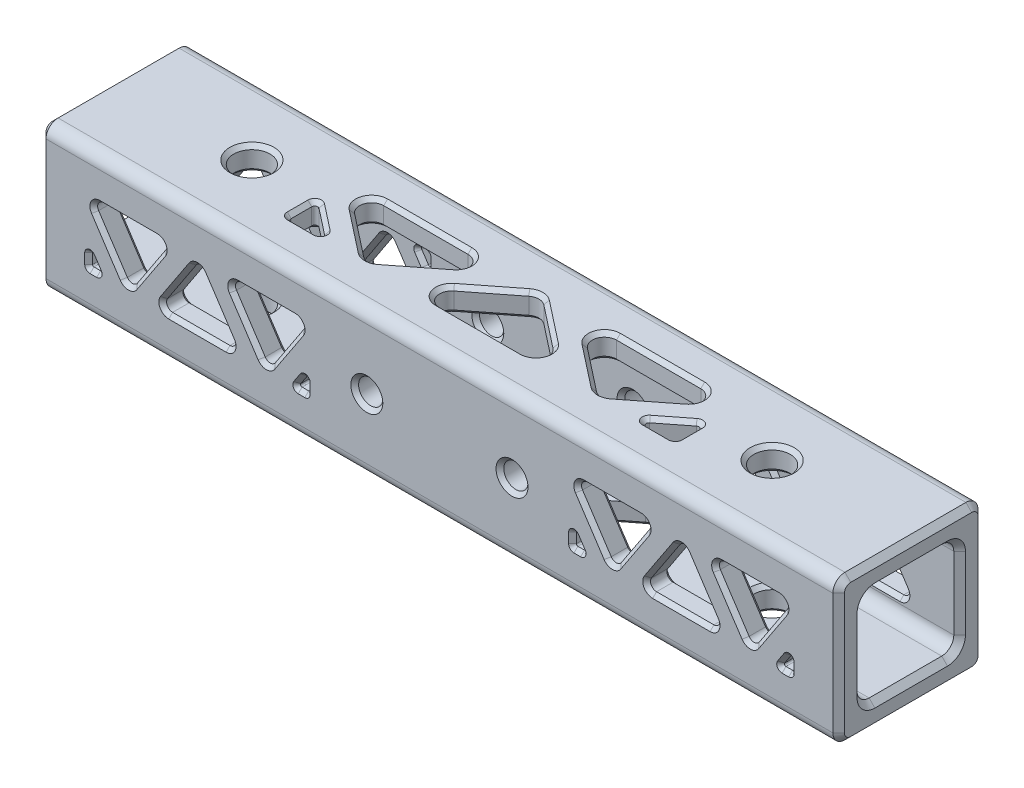
from build123d import *

# Parameters (mm, degrees)
SKETCH1_W                      = 19.05
SKETCH1_H                      = 19.05
SKETCH1_W_2                    = 12.7
SKETCH1_H_2                    = 12.7
BOSS_EXTRUDE1_DEPTH            = 52.3875
F_3_16_0_1875_DIAMETER_HOLE1_D = 4.7625
F_1_8_0_125_DIAMETER_HOLE1_D   = 3.175
CUT_EXTRUDE1_DEPTH             = 3.175
CUT_EXTRUDE2_DEPTH             = 3.175
CIRPATTERN1_COUNT              = 2
CIRPATTERN2_COUNT              = 2
FILLET1_R                      = 1.5875
FILLET4_R                      = 0.79375
FILLET2_R                      = 0.396875
FILLET3_R                      = 0.1984375
CHAMFER1_SIZE                  = 0.762
CHAMFER2_SIZE                  = 0.508


with BuildPart() as part:
    # Sketch1 → Boss-Extrude1 (new body, symmetric)
    with BuildSketch(Plane(origin=(0, 0, 0), x_dir=(0, 0, -1), z_dir=(1, 0, 0))):
        Rectangle(SKETCH1_W, SKETCH1_H)
        Rectangle(SKETCH1_W_2, SKETCH1_H_2, mode=Mode.SUBTRACT)
    extrude(amount=BOSS_EXTRUDE1_DEPTH, both=True)

    # 3/16 (0.1875) Diameter Hole1 (through all)
    with Locations(Plane(origin=(0, 9.525, 0), x_dir=(1, 0, 0), z_dir=(0, 1, 0))):
        with Locations((-34.13125, 0), (34.13125, 0)):
            Hole(F_3_16_0_1875_DIAMETER_HOLE1_D / 2)

    # 1/8 (0.125) Diameter Hole1 (through all)
    with Locations(Plane(origin=(0, 0, -9.525), x_dir=(-1, 0, 0), z_dir=(0, 0, -1))):
        with Locations((-9.525, 0), (9.525, 0)):
            Hole(F_1_8_0_125_DIAMETER_HOLE1_D / 2)

    # Sketch8 → Cut-Extrude1 (cut)
    with BuildSketch(Plane(origin=(0, 9.525, 0), x_dir=(1, 0, 0), z_dir=(0, 1, 0))):
        Polygon((-25.4, -0.065347152), (-25.4, -3.96875), (-20.420043773, -3.96875), align=None)
        Polygon((-25.4, 3.96875), (-15.273347924, -3.96875), (-5.146695849, 3.96875), align=None)
        Polygon((-10.126652076, -3.96875), (0, 3.96875), (10.126652076, -3.96875), align=None)
        Polygon((25.4, 3.96875), (15.273347924, -3.96875), (5.146695849, 3.96875), align=None)
        Polygon((25.4, -3.96875), (25.4, -0.065347152), (20.420043773, -3.96875), align=None)
    cut_extrude1 = extrude(amount=-CUT_EXTRUDE1_DEPTH, mode=Mode.SUBTRACT)

    # Sketch9 → Cut-Extrude2 (cut)
    with BuildSketch(Plane.XY.offset(9.525)):
        Polygon((-46.0375, 3.96875), (-40.796126441, -3.96875), (-35.554752881, 3.96875), align=None)
        Polygon((-36.991373559, -3.96875), (-31.75, 3.96875), (-26.508626441, -3.96875), align=None)
        Polygon((-17.4625, 3.96875), (-22.703873559, -3.96875), (-27.945247119, 3.96875), align=None)
        Polygon((-46.0375, -1.793141545), (-46.0375, -3.96875), (-44.600879322, -3.96875), align=None)
        Polygon((-17.4625, -3.96875), (-17.4625, -1.793141545), (-18.899120678, -3.96875), align=None)
        Polygon((17.4625, 3.96875), (22.703873559, -3.96875), (27.945247119, 3.96875), align=None)
        Polygon((26.508626441, -3.96875), (31.75, 3.96875), (36.991373559, -3.96875), align=None)
        Polygon((46.0375, 3.96875), (40.796126441, -3.96875), (35.554752881, 3.96875), align=None)
        Polygon((17.4625, -1.793141545), (17.4625, -3.96875), (18.899120678, -3.96875), align=None)
        Polygon((46.0375, -1.793141545), (46.0375, -3.96875), (44.600879322, -3.96875), align=None)
    cut_extrude2 = extrude(amount=-CUT_EXTRUDE2_DEPTH, mode=Mode.SUBTRACT)

    # CirPattern1: Cut-Extrude1 ×2 about axis
    cirpattern1_axis = Axis((57.62625, 0, 0), (-1, 0, 0))
    for i in range(1, CIRPATTERN1_COUNT):
        add(cut_extrude1.rotate(cirpattern1_axis, i * 360 / CIRPATTERN1_COUNT), mode=Mode.SUBTRACT)

    # CirPattern2: Cut-Extrude2 ×2 about axis
    cirpattern2_axis = Axis((57.62625, 0, 0), (-1, 0, 0))
    for i in range(1, CIRPATTERN2_COUNT):
        add(cut_extrude2.rotate(cirpattern2_axis, i * 360 / CIRPATTERN2_COUNT), mode=Mode.SUBTRACT)

    # Fillet1
    fillet1_edges = [part.edges().sort_by_distance(p)[0] for p in [
        (0, -6.35, -6.35),
        (0, 6.35, -6.35),
        (0, 6.35, 6.35),
        (0, -6.35, 6.35),
        (5.146695849, -7.9375, 3.96875),
        (25.4, -7.9375, 3.96875),
        (15.273347924, -7.9375, -3.96875),
        (10.126652076, -7.9375, -3.96875),
        (0, -7.9375, 3.96875),
        (-10.126652076, -7.9375, -3.96875),
        (-25.4, -7.9375, 3.96875),
        (-5.146695849, -7.9375, 3.96875),
        (-15.273347924, -7.9375, -3.96875),
        (0, -9.525, -9.525),
        (0, -9.525, 9.525),
        (0, 9.525, 9.525),
        (0, 9.525, -9.525),
        (5.146695849, 7.9375, -3.96875),
        (25.4, 7.9375, -3.96875),
        (15.273347924, 7.9375, 3.96875),
        (0, 7.9375, -3.96875),
        (10.126652076, 7.9375, 3.96875),
        (-10.126652076, 7.9375, 3.96875),
        (-25.4, 7.9375, -3.96875),
        (-5.146695849, 7.9375, -3.96875),
        (-15.273347924, 7.9375, 3.96875),
    ]]
    fillet(fillet1_edges, radius=FILLET1_R)

    # Fillet4
    fillet4_edges = [part.edges().sort_by_distance(p)[0] for p in [
        (-22.703873559, -3.96875, 7.9375),
        (-17.4625, 3.96875, 7.9375),
        (-27.945247119, 3.96875, 7.9375),
        (-40.796126441, -3.96875, 7.9375),
        (-35.554752881, 3.96875, 7.9375),
        (-46.0375, 3.96875, 7.9375),
        (22.703873559, -3.96875, 7.9375),
        (27.945247119, 3.96875, 7.9375),
        (17.4625, 3.96875, 7.9375),
        (40.796126441, -3.96875, 7.9375),
        (46.0375, 3.96875, 7.9375),
        (35.554752881, 3.96875, 7.9375),
        (26.508626441, -3.96875, 7.9375),
        (36.991373559, -3.96875, 7.9375),
        (31.75, 3.96875, 7.9375),
        (-36.991373559, -3.96875, 7.9375),
        (-26.508626441, -3.96875, 7.9375),
        (-31.75, 3.96875, 7.9375),
        (-27.945247119, -3.96875, -7.9375),
        (-17.4625, -3.96875, -7.9375),
        (-22.703873559, 3.96875, -7.9375),
        (-46.0375, -3.96875, -7.9375),
        (-35.554752881, -3.96875, -7.9375),
        (-40.796126441, 3.96875, -7.9375),
        (17.4625, -3.96875, -7.9375),
        (27.945247119, -3.96875, -7.9375),
        (22.703873559, 3.96875, -7.9375),
        (35.554752881, -3.96875, -7.9375),
        (46.0375, -3.96875, -7.9375),
        (40.796126441, 3.96875, -7.9375),
        (36.991373559, 3.96875, -7.9375),
        (31.75, -3.96875, -7.9375),
        (26.508626441, 3.96875, -7.9375),
        (-26.508626441, 3.96875, -7.9375),
        (-31.75, -3.96875, -7.9375),
        (-36.991373559, 3.96875, -7.9375),
    ]]
    fillet(fillet4_edges, radius=FILLET4_R)

    # Fillet2
    fillet2_edges = [part.edges().sort_by_distance(p)[0] for p in [
        (25.4, -7.9375, -3.96875),
        (20.420043773, -7.9375, -3.96875),
        (25.4, -7.9375, -0.065347152),
        (-20.420043773, -7.9375, -3.96875),
        (-25.4, -7.9375, -3.96875),
        (-25.4, -7.9375, -0.065347152),
        (25.4, 7.9375, 3.96875),
        (20.420043773, 7.9375, 3.96875),
        (25.4, 7.9375, 0.065347152),
        (-20.420043773, 7.9375, 3.96875),
        (-25.4, 7.9375, 3.96875),
        (-25.4, 7.9375, 0.065347152),
    ]]
    fillet(fillet2_edges, radius=FILLET2_R)

    # Fillet3
    fillet3_edges = [part.edges().sort_by_distance(p)[0] for p in [
        (-17.4625, -1.793141545, 7.9375),
        (-18.899120678, -3.96875, 7.9375),
        (-17.4625, -3.96875, 7.9375),
        (-46.0375, -1.793141545, 7.9375),
        (-46.0375, -3.96875, 7.9375),
        (-44.600879322, -3.96875, 7.9375),
        (17.4625, -1.793141545, 7.9375),
        (17.4625, -3.96875, 7.9375),
        (18.899120678, -3.96875, 7.9375),
        (46.0375, -1.793141545, 7.9375),
        (44.600879322, -3.96875, 7.9375),
        (46.0375, -3.96875, 7.9375),
        (-17.4625, 3.96875, -7.9375),
        (-17.4625, 1.793141545, -7.9375),
        (-18.899120678, 3.96875, -7.9375),
        (-44.600879322, 3.96875, -7.9375),
        (-46.0375, 3.96875, -7.9375),
        (-46.0375, 1.793141545, -7.9375),
        (18.899120678, 3.96875, -7.9375),
        (17.4625, 3.96875, -7.9375),
        (17.4625, 1.793141545, -7.9375),
        (46.0375, 3.96875, -7.9375),
        (46.0375, 1.793141545, -7.9375),
        (44.600879322, 3.96875, -7.9375),
    ]]
    fillet(fillet3_edges, radius=FILLET3_R)

    # Chamfer1
    chamfer1_edges = [part.edges().sort_by_distance(p)[0] for p in [
        (-52.3875, -6.35, 0),
        (52.3875, -6.35, 0),
        (-52.3875, 0, -6.35),
        (52.3875, 0, -6.35),
        (-52.3875, 6.35, 0),
        (52.3875, 6.35, 0),
        (-52.3875, 0, 6.35),
        (52.3875, 0, 6.35),
        (-52.3875, 0, -9.525),
        (52.3875, 0, -9.525),
        (-52.3875, -9.525, 0),
        (-52.3875, 0, 9.525),
        (-52.3875, 9.525, 0),
        (-52.3875, 9.060032015, 9.060032015),
        (-52.3875, -9.060032015, 9.060032015),
        (-52.3875, 9.060032015, -9.060032015),
        (-52.3875, -9.060032015, -9.060032015),
        (52.3875, -9.525, 0),
        (52.3875, 9.525, 0),
        (52.3875, 0, 9.525),
        (52.3875, 9.060032015, 9.060032015),
        (52.3875, -9.060032015, 9.060032015),
        (52.3875, 9.060032015, -9.060032015),
        (52.3875, -9.060032015, -9.060032015),
        (-52.3875, -5.885032015, -5.885032015),
        (52.3875, -5.885032015, -5.885032015),
        (-52.3875, 5.885032015, -5.885032015),
        (52.3875, 5.885032015, -5.885032015),
        (-52.3875, 5.885032015, 5.885032015),
        (52.3875, 5.885032015, 5.885032015),
        (-52.3875, -5.885032015, 5.885032015),
        (52.3875, -5.885032015, 5.885032015),
    ]]
    chamfer(chamfer1_edges, length=CHAMFER1_SIZE)

    # Chamfer2
    chamfer2_edges = [part.edges().sort_by_distance(p)[0] for p in [
        (36.5125, 6.35, 0),
        (36.5125, -6.35, 0),
        (36.5125, -9.525, 0),
        (36.5125, 9.525, 0),
        (15.273347924, -9.525, 3.96875),
        (15.273347924, -6.35, 3.96875),
        (19.01666457, -9.525, -1.034653356),
        (19.01666457, -6.35, -1.034653356),
        (11.530031279, -9.525, -1.034653356),
        (11.530031279, -6.35, -1.034653356),
        (-3.743316645, -9.525, 1.034653356),
        (-3.743316645, -6.35, 1.034653356),
        (3.743316645, -9.525, 1.034653356),
        (3.743316645, -6.35, 1.034653356),
        (0, -9.525, -3.96875),
        (0, -6.35, -3.96875),
        (-15.273347924, -9.525, 3.96875),
        (-15.273347924, -6.35, 3.96875),
        (-31.75, 6.35, 0),
        (-31.75, -6.35, 0),
        (-11.530031279, -9.525, -1.034653356),
        (-11.530031279, -6.35, -1.034653356),
        (-31.75, -9.525, 0),
        (-31.75, 9.525, 0),
        (-19.01666457, -9.525, -1.034653356),
        (-19.01666457, -6.35, -1.034653356),
        (15.273347924, 9.525, -3.96875),
        (15.273347924, 6.35, -3.96875),
        (19.01666457, 9.525, 1.034653356),
        (19.01666457, 6.35, 1.034653356),
        (11.530031279, 9.525, 1.034653356),
        (11.530031279, 6.35, 1.034653356),
        (3.743316645, 9.525, -1.034653356),
        (3.743316645, 6.35, -1.034653356),
        (0, 9.525, 3.96875),
        (0, 6.35, 3.96875),
        (-3.743316645, 9.525, -1.034653356),
        (-3.743316645, 6.35, -1.034653356),
        (-15.273347924, 9.525, -3.96875),
        (-15.273347924, 6.35, -3.96875),
        (-11.530031279, 9.525, 1.034653356),
        (-11.530031279, 6.35, 1.034653356),
        (-19.01666457, 9.525, 1.034653356),
        (-19.01666457, 6.35, 1.034653356),
        (22.301925311, -9.525, 2.899270205),
        (22.301925311, -6.35, 2.899270205),
        (8.244770538, -9.525, 2.899270205),
        (8.244770538, -6.35, 2.899270205),
        (15.273347924, -9.525, -3.539201424),
        (15.273347924, -6.35, -3.539201424),
        (0, -9.525, 3.539201424),
        (0, -6.35, 3.539201424),
        (7.028577387, -9.525, -2.899270205),
        (7.028577387, -6.35, -2.899270205),
        (-7.028577387, -9.525, -2.899270205),
        (-7.028577387, -6.35, -2.899270205),
        (-8.244770538, -9.525, 2.899270205),
        (-8.244770538, -6.35, 2.899270205),
        (-22.301925311, -9.525, 2.899270205),
        (-22.301925311, -6.35, 2.899270205),
        (-15.273347924, -9.525, -3.539201424),
        (-15.273347924, -6.35, -3.539201424),
        (22.301925311, 9.525, -2.899270205),
        (22.301925311, 6.35, -2.899270205),
        (8.244770538, 9.525, -2.899270205),
        (8.244770538, 6.35, -2.899270205),
        (15.273347924, 9.525, 3.539201424),
        (15.273347924, 6.35, 3.539201424),
        (7.028577387, 9.525, 2.899270205),
        (7.028577387, 6.35, 2.899270205),
        (0, 9.525, -3.539201424),
        (0, 6.35, -3.539201424),
        (-7.028577387, 9.525, 2.899270205),
        (-7.028577387, 6.35, 2.899270205),
        (-8.244770538, 9.525, -2.899270205),
        (-8.244770538, 6.35, -2.899270205),
        (-22.301925311, 9.525, -2.899270205),
        (-22.301925311, 6.35, -2.899270205),
        (-15.273347924, 9.525, 3.539201424),
        (-15.273347924, 6.35, 3.539201424),
        (7.9375, 0, 6.35),
        (7.9375, 0, -6.35),
        (7.9375, 0, -9.525),
        (7.9375, 0, 9.525),
        (-38.250731901, 0.11402205, -9.525),
        (-38.250731901, 0.11402205, -6.35),
        (-43.34152098, 0.11402205, -9.525),
        (-43.34152098, 0.11402205, -6.35),
        (-40.796126441, -3.96875, -9.525),
        (-40.796126441, -3.96875, -6.35),
        (-31.75, 3.96875, -9.525),
        (-31.75, 3.96875, -6.35),
        (-34.295394539, -0.11402205, -9.525),
        (-34.295394539, -0.11402205, -6.35),
        (-29.204605461, -0.11402205, -9.525),
        (-29.204605461, -0.11402205, -6.35),
        (-25.249268099, 0.11402205, -9.525),
        (-25.249268099, 0.11402205, -6.35),
        (-22.703873559, -3.96875, -9.525),
        (-22.703873559, -3.96875, -6.35),
        (-20.15847902, 0.11402205, -9.525),
        (-20.15847902, 0.11402205, -6.35),
        (20.15847902, 0.11402205, -9.525),
        (20.15847902, 0.11402205, -6.35),
        (22.703873559, -3.96875, -9.525),
        (22.703873559, -3.96875, -6.35),
        (25.249268099, 0.11402205, -9.525),
        (25.249268099, 0.11402205, -6.35),
        (31.75, 3.96875, -9.525),
        (-11.1125, 0, -6.35),
        (31.75, 3.96875, -6.35),
        (-11.1125, 0, 6.35),
        (29.204605461, -0.11402205, -9.525),
        (-11.1125, 0, 9.525),
        (29.204605461, -0.11402205, -6.35),
        (-11.1125, 0, -9.525),
        (34.295394539, -0.11402205, -9.525),
        (34.295394539, -0.11402205, -6.35),
        (38.250731901, 0.11402205, -9.525),
        (38.250731901, 0.11402205, -6.35),
        (40.796126441, -3.96875, -9.525),
        (40.796126441, -3.96875, -6.35),
        (43.34152098, 0.11402205, -9.525),
        (43.34152098, 0.11402205, -6.35),
        (40.796126441, 3.96875, 9.525),
        (40.796126441, 3.96875, 6.35),
        (43.34152098, -0.11402205, 9.525),
        (43.34152098, -0.11402205, 6.35),
        (38.250731901, -0.11402205, 9.525),
        (38.250731901, -0.11402205, 6.35),
        (29.204605461, 0.11402205, 9.525),
        (29.204605461, 0.11402205, 6.35),
        (34.295394539, 0.11402205, 9.525),
        (34.295394539, 0.11402205, 6.35),
        (31.75, -3.96875, 9.525),
        (31.75, -3.96875, 6.35),
        (20.15847902, -0.11402205, 9.525),
        (20.15847902, -0.11402205, 6.35),
        (22.703873559, 3.96875, 9.525),
        (22.703873559, 3.96875, 6.35),
        (25.249268099, -0.11402205, 9.525),
        (25.249268099, -0.11402205, 6.35),
        (-22.703873559, 3.96875, 9.525),
        (-22.703873559, 3.96875, 6.35),
        (-20.15847902, -0.11402205, 9.525),
        (-20.15847902, -0.11402205, 6.35),
        (-25.249268099, -0.11402205, 9.525),
        (-25.249268099, -0.11402205, 6.35),
        (-29.204605461, 0.11402205, 9.525),
        (-29.204605461, 0.11402205, 6.35),
        (-31.75, -3.96875, 9.525),
        (-31.75, -3.96875, 6.35),
        (-34.295394539, 0.11402205, 9.525),
        (-34.295394539, 0.11402205, 6.35),
        (-40.796126441, 3.96875, 9.525),
        (-40.796126441, 3.96875, 6.35),
        (-38.250731901, -0.11402205, 9.525),
        (-38.250731901, -0.11402205, 6.35),
        (-43.34152098, -0.11402205, 9.525),
        (-43.34152098, -0.11402205, 6.35),
        (-40.796126441, 3.322027114, -9.525),
        (-40.796126441, 3.322027114, -6.35),
        (-45.261178075, -3.551075734, -9.525),
        (-45.261178075, -3.551075734, -6.35),
        (-36.331074806, -3.551075734, -9.525),
        (-36.331074806, -3.551075734, -6.35),
        (-36.215051635, 3.551075734, -9.525),
        (-36.215051635, 3.551075734, -6.35),
        (-27.284948365, 3.551075734, -9.525),
        (-27.284948365, 3.551075734, -6.35),
        (-31.75, -3.322027114, -9.525),
        (-31.75, -3.322027114, -6.35),
        (-27.168925194, -3.551075734, -9.525),
        (-27.168925194, -3.551075734, -6.35),
        (-18.238821925, -3.551075734, -9.525),
        (-18.238821925, -3.551075734, -6.35),
        (-22.703873559, 3.322027114, -9.525),
        (-22.703873559, 3.322027114, -6.35),
        (18.238821925, -3.551075734, -9.525),
        (18.238821925, -3.551075734, -6.35),
        (27.168925194, -3.551075734, -9.525),
        (27.168925194, -3.551075734, -6.35),
        (22.703873559, 3.322027114, -9.525),
        (22.703873559, 3.322027114, -6.35),
        (27.284948365, 3.551075734, -9.525),
        (27.284948365, 3.551075734, -6.35),
        (36.215051635, 3.551075734, -9.525),
        (36.215051635, 3.551075734, -6.35),
        (31.75, -3.322027114, -9.525),
        (31.75, -3.322027114, -6.35),
        (36.331074806, -3.551075734, -9.525),
        (36.331074806, -3.551075734, -6.35),
        (40.796126441, 3.322027114, -9.525),
        (40.796126441, 3.322027114, -6.35),
        (45.261178075, -3.551075734, -9.525),
        (45.261178075, -3.551075734, -6.35),
        (45.261178075, 3.551075734, 9.525),
        (45.261178075, 3.551075734, 6.35),
        (40.796126441, -3.322027114, 9.525),
        (40.796126441, -3.322027114, 6.35),
        (36.331074806, 3.551075734, 9.525),
        (36.331074806, 3.551075734, 6.35),
        (31.75, 3.322027114, 9.525),
        (31.75, 3.322027114, 6.35),
        (36.215051635, -3.551075734, 9.525),
        (36.215051635, -3.551075734, 6.35),
        (27.284948365, -3.551075734, 9.525),
        (27.284948365, -3.551075734, 6.35),
        (18.238821925, 3.551075734, 9.525),
        (18.238821925, 3.551075734, 6.35),
        (27.168925194, 3.551075734, 9.525),
        (27.168925194, 3.551075734, 6.35),
        (22.703873559, -3.322027114, 9.525),
        (22.703873559, -3.322027114, 6.35),
        (-18.238821925, 3.551075734, 9.525),
        (-18.238821925, 3.551075734, 6.35),
        (-22.703873559, -3.322027114, 9.525),
        (-22.703873559, -3.322027114, 6.35),
        (-27.168925194, 3.551075734, 9.525),
        (-27.168925194, 3.551075734, 6.35),
        (-27.284948365, -3.551075734, 9.525),
        (-27.284948365, -3.551075734, 6.35),
        (-36.215051635, -3.551075734, 9.525),
        (-36.215051635, -3.551075734, 6.35),
        (-31.75, 3.322027114, 9.525),
        (-31.75, 3.322027114, 6.35),
        (-36.331074806, 3.551075734, 9.525),
        (-36.331074806, 3.551075734, 6.35),
        (-40.796126441, -3.322027114, 9.525),
        (-40.796126441, -3.322027114, 6.35),
        (-45.261178075, 3.551075734, 9.525),
        (-45.261178075, 3.551075734, 6.35),
        (23.286419179, 9.525, 3.96875),
        (23.286419179, 6.35, 3.96875),
        (23.041586735, 9.525, 1.913925059),
        (23.041586735, 6.35, 1.913925059),
        (25.4, 9.525, 2.22628197),
        (25.4, 6.35, 2.22628197),
        (-25.4, 9.525, 2.22628197),
        (-25.4, 6.35, 2.22628197),
        (-23.041586735, 9.525, 1.913925059),
        (-23.041586735, 6.35, 1.913925059),
        (-23.286419179, 9.525, 3.96875),
        (-23.286419179, 6.35, 3.96875),
        (-25.4, -9.525, -2.22628197),
        (-25.4, -6.35, -2.22628197),
        (-23.041586735, -9.525, -1.913925059),
        (-23.041586735, -6.35, -1.913925059),
        (-23.286419179, -9.525, -3.96875),
        (-23.286419179, -6.35, -3.96875),
        (23.286419179, -9.525, -3.96875),
        (23.286419179, -6.35, -3.96875),
        (23.041586735, -9.525, -1.913925059),
        (23.041586735, -6.35, -1.913925059),
        (25.4, -9.525, -2.22628197),
        (25.4, -6.35, -2.22628197),
        (21.194562446, 9.525, 3.701380051),
        (21.194562446, 6.35, 3.701380051),
        (25.176822854, 9.525, 0.523843285),
        (25.176822854, 6.35, 0.523843285),
        (25.283758004, 9.525, 3.852508004),
        (25.283758004, 6.35, 3.852508004),
        (-25.176822854, 9.525, 0.523843285),
        (-25.176822854, 6.35, 0.523843285),
        (-21.194562446, 9.525, 3.701380051),
        (-21.194562446, 6.35, 3.701380051),
        (-25.283758004, 9.525, 3.852508004),
        (-25.283758004, 6.35, 3.852508004),
        (-25.176822854, -9.525, -0.523843285),
        (-25.176822854, -6.35, -0.523843285),
        (-21.194562446, -9.525, -3.701380051),
        (-21.194562446, -6.35, -3.701380051),
        (-25.283758004, -9.525, -3.852508004),
        (-25.283758004, -6.35, -3.852508004),
        (21.194562446, -9.525, -3.701380051),
        (21.194562446, -6.35, -3.701380051),
        (25.176822854, -9.525, -0.523843285),
        (25.176822854, -6.35, -0.523843285),
        (25.283758004, -9.525, -3.852508004),
        (25.283758004, -6.35, -3.852508004),
        (-45.404386608, 3.96875, -9.525),
        (-45.404386608, 3.96875, -6.35),
        (-46.0375, 3.112042324, -9.525),
        (-46.0375, 3.112042324, -6.35),
        (-45.238793971, 3.002696451, -9.525),
        (-45.238793971, 3.002696451, -6.35),
        (-18.095613392, 3.96875, -9.525),
        (-18.095613392, 3.96875, -6.35),
        (-18.261206029, 3.002696451, -9.525),
        (-18.261206029, 3.002696451, -6.35),
        (-17.4625, 3.112042324, -9.525),
        (-17.4625, 3.112042324, -6.35),
        (18.095613392, 3.96875, -9.525),
        (18.095613392, 3.96875, -6.35),
        (17.4625, 3.112042324, -9.525),
        (17.4625, 3.112042324, -6.35),
        (18.261206029, 3.002696451, -9.525),
        (18.261206029, 3.002696451, -6.35),
        (45.404386608, 3.96875, -9.525),
        (45.404386608, 3.96875, -6.35),
        (45.238793971, 3.002696451, -9.525),
        (45.238793971, 3.002696451, -6.35),
        (46.0375, 3.112042324, -9.525),
        (46.0375, 3.112042324, -6.35),
        (46.0375, -3.112042324, 9.525),
        (46.0375, -3.112042324, 6.35),
        (45.404386608, -3.96875, 9.525),
        (45.404386608, -3.96875, 6.35),
        (45.238793971, -3.002696451, 9.525),
        (45.238793971, -3.002696451, 6.35),
        (18.261206029, -3.002696451, 9.525),
        (18.261206029, -3.002696451, 6.35),
        (18.095613392, -3.96875, 9.525),
        (18.095613392, -3.96875, 6.35),
        (17.4625, -3.112042324, 9.525),
        (17.4625, -3.112042324, 6.35),
        (-18.095613392, -3.96875, 9.525),
        (-18.095613392, -3.96875, 6.35),
        (-18.261206029, -3.002696451, 9.525),
        (-18.261206029, -3.002696451, 6.35),
        (-17.4625, -3.112042324, 9.525),
        (-17.4625, -3.112042324, 6.35),
        (-45.238793971, -3.002696451, 9.525),
        (-45.238793971, -3.002696451, 6.35),
        (-45.404386608, -3.96875, 9.525),
        (-45.404386608, -3.96875, 6.35),
        (-46.0375, -3.112042324, 9.525),
        (-46.0375, -3.112042324, 6.35),
        (-45.979379002, 3.910629002, -9.525),
        (-45.979379002, 3.910629002, -6.35),
        (-45.89614863, 2.263723168, -9.525),
        (-45.89614863, 2.263723168, -6.35),
        (-44.794959803, 3.864331433, -9.525),
        (-44.794959803, 3.864331433, -6.35),
        (-18.705040197, 3.864331433, -9.525),
        (-18.705040197, 3.864331433, -6.35),
        (-17.60385137, 2.263723168, -9.525),
        (-17.60385137, 2.263723168, -6.35),
        (-17.520620998, 3.910629002, -9.525),
        (-17.520620998, 3.910629002, -6.35),
        (17.520620998, 3.910629002, -9.525),
        (17.520620998, 3.910629002, -6.35),
        (17.60385137, 2.263723168, -9.525),
        (17.60385137, 2.263723168, -6.35),
        (18.705040197, 3.864331433, -9.525),
        (18.705040197, 3.864331433, -6.35),
        (44.794959803, 3.864331433, -9.525),
        (44.794959803, 3.864331433, -6.35),
        (45.979379002, 3.910629002, -9.525),
        (45.979379002, 3.910629002, -6.35),
        (45.89614863, 2.263723168, -9.525),
        (45.89614863, 2.263723168, -6.35),
        (45.979379002, -3.910629002, 9.525),
        (45.979379002, -3.910629002, 6.35),
        (45.89614863, -2.263723168, 9.525),
        (45.89614863, -2.263723168, 6.35),
        (44.794959803, -3.864331433, 9.525),
        (44.794959803, -3.864331433, 6.35),
        (18.705040197, -3.864331433, 9.525),
        (18.705040197, -3.864331433, 6.35),
        (17.60385137, -2.263723168, 9.525),
        (17.60385137, -2.263723168, 6.35),
        (17.520620998, -3.910629002, 9.525),
        (17.520620998, -3.910629002, 6.35),
        (-18.705040197, -3.864331433, 9.525),
        (-18.705040197, -3.864331433, 6.35),
        (-17.60385137, -2.263723168, 9.525),
        (-17.60385137, -2.263723168, 6.35),
        (-17.520620998, -3.910629002, 9.525),
        (-17.520620998, -3.910629002, 6.35),
        (-44.794959803, -3.864331433, 9.525),
        (-44.794959803, -3.864331433, 6.35),
        (-45.89614863, -2.263723168, 9.525),
        (-45.89614863, -2.263723168, 6.35),
        (-45.979379002, -3.910629002, 9.525),
        (-45.979379002, -3.910629002, 6.35),
    ]]
    chamfer(chamfer2_edges, length=CHAMFER2_SIZE)


solid = part.part
